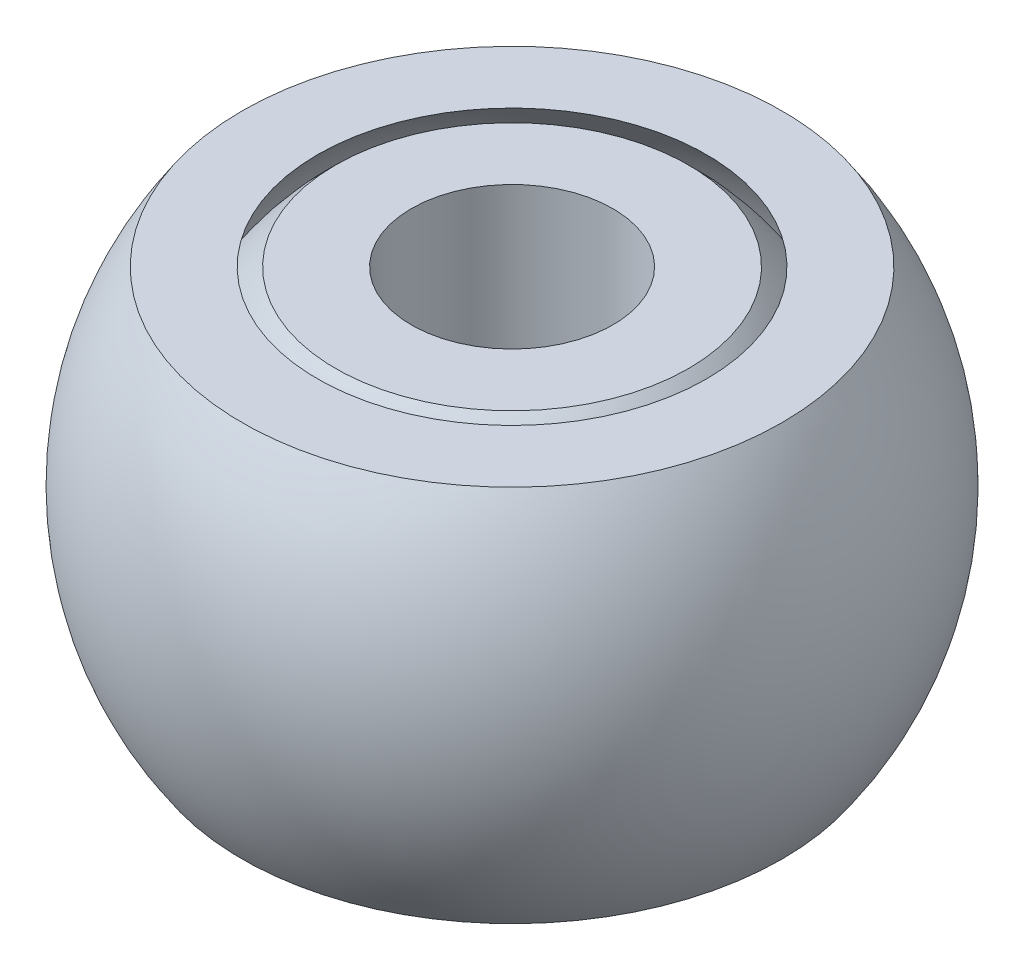
from build123d import *

# Parameters (mm, degrees)
CROQUIS3_W            = 7
CROQUIS3_H            = 7
CORTAR_EXTRUIR1_DEPTH = 1


with BuildPart() as part:
    # Croquis2 → Revolución1 (revolve)
    with BuildSketch(Plane.XY):
        with BuildLine():
            Line((-7.714216892, 7.5), (-10.714216892, 7.5))
            ThreePointArc((-10.714216892, 7.5), (-13.078396064, 0), (-10.714216892, -7.5))
            Line((-10.714216892, -7.5), (-7.714216892, -7.5))
            ThreePointArc((-7.714216892, -7.5), (-10.759142264, 0), (-7.714216892, 7.5))
        make_face()
        with BuildLine():
            Line((-4, 7.5), (-4, -7.5))
            Line((-4, -7.5), (-7, -7.5))
            ThreePointArc((-7, -7.5), (-10.259142264, 0), (-7, 7.5))
            Line((-7, 7.5), (-4, 7.5))
        make_face()
    revolve(axis=Axis((0, 7.5, 0), (0, -1, 0)))

    # Croquis3 → Cortar-Extruir1 (cut)
    with BuildSketch(Plane(origin=(-13.078396064, 0, 0), x_dir=(0, 0, -1), z_dir=(1, 0, 0))):
        Rectangle(CROQUIS3_W, CROQUIS3_H)
    extrude(amount=CORTAR_EXTRUIR1_DEPTH, mode=Mode.SUBTRACT)


solid = part.part
